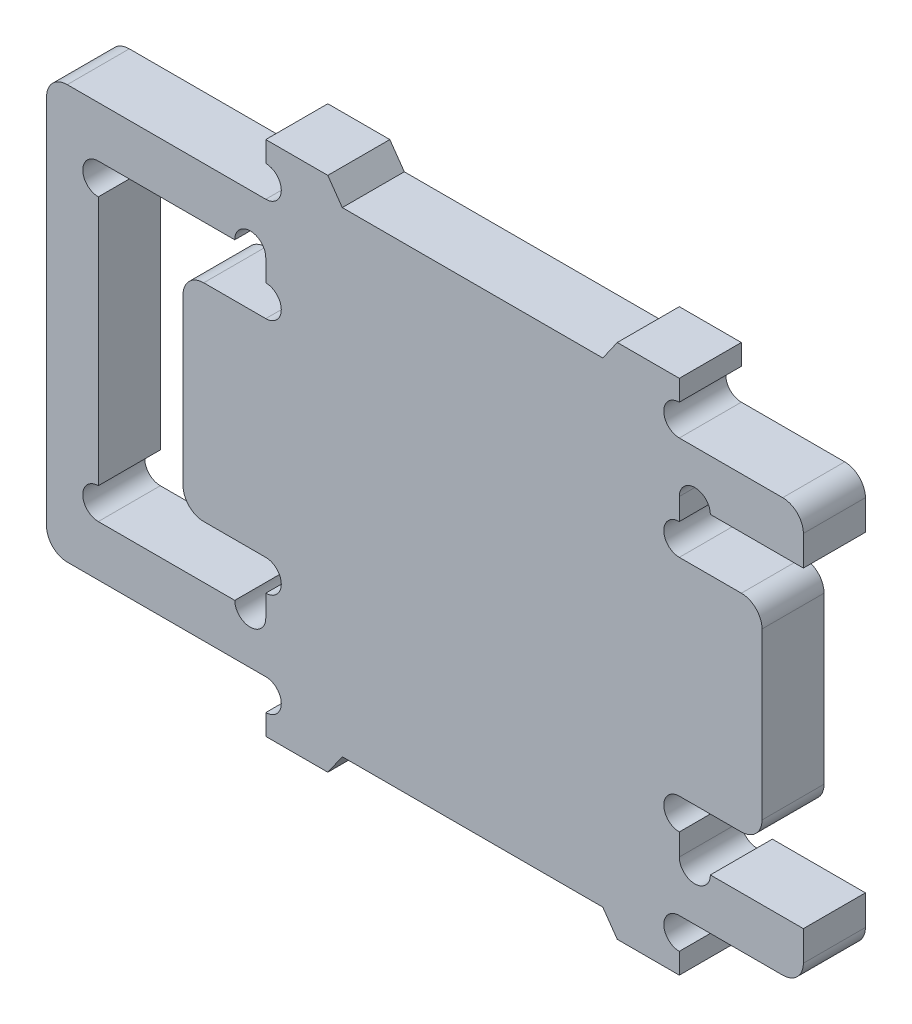
from build123d import *

# Parameters (mm, degrees)
EXTRUDE_1_DEPTH     = 1.5
FILLET_1_R          = 1
SKETCH_3_R          = 0.75
CUT_EXTRUDE_1_DEPTH = 4
SKETCH_4_R          = 0.75
CUT_EXTRUDE_2_DEPTH = 4
SKETCH_5_R          = 0.75
CUT_EXTRUDE_3_DEPTH = 4
CUT_EXTRUDE_6_DEPTH = 4


with BuildPart() as part:
    # 草图1 → 凸台-拉伸1 (new body, symmetric)
    with BuildSketch(Plane.XY):
        Polygon((0, 10), (10.6, 10), (10.6, 12.5), (30.6, 12.5), (30.6, 10), (36.6, 10), (36.6, 7.55), (30.6, 7.55), (30.6, 5), (34.6, 5), (34.6, -5), (30.6, -5), (30.6, -7.55), (36.6, -7.55), (36.6, -10), (30.6, -10), (30.6, -12.5), (10.6, -12.5), (10.6, -10), (0, -10), align=None)
        Polygon((6.6, 5), (10.6, 5), (10.6, 7.55), (2.5, 7.55), (2.5, -7.55), (10.6, -7.55), (10.6, -5), (6.6, -5), align=None, mode=Mode.SUBTRACT)
    extrude(amount=EXTRUDE_1_DEPTH, both=True)

    # 圆角1
    fillet_1_edges = [part.edges().sort_by_distance(p)[0] for p in [
        (0, 10, 0),
        (36.6, 10, 0),
        (34.6, 5, 0),
        (34.6, -5, 0),
        (36.6, -10, 0),
        (0, -10, 0),
        (6.6, -5, 0),
        (6.6, 5, 0),
    ]]
    fillet(fillet_1_edges, radius=FILLET_1_R)

    # 草图3 → 切除-拉伸1 (cut, through all)
    with BuildSketch(Plane.XY.offset(1.5)):
        with Locations((9.85, 7.55)):
            Circle(SKETCH_3_R)
        with Locations((9.85, -7.55)):
            Circle(SKETCH_3_R)
        with Locations((31.35, 7.55)):
            Circle(SKETCH_3_R)
        with Locations((30.6, 5.75)):
            Circle(SKETCH_3_R)
        with Locations((30.6, -5.75)):
            Circle(SKETCH_3_R)
        with Locations((31.35, -7.55)):
            Circle(SKETCH_3_R)
        with Locations((10.6, 5.75)):
            Circle(SKETCH_3_R)
        with Locations((10.6, -5.75)):
            Circle(SKETCH_3_R)
    extrude(amount=-CUT_EXTRUDE_1_DEPTH, mode=Mode.SUBTRACT)

    # 草图4 → 切除-拉伸2 (cut, through all)
    with BuildSketch(Plane.XY.offset(1.5)):
        with Locations((10.6, 10.75)):
            Circle(SKETCH_4_R)
        with Locations((30.6, 10.75)):
            Circle(SKETCH_4_R)
        with Locations((10.6, -10.75)):
            Circle(SKETCH_4_R)
        with Locations((30.6, -10.75)):
            Circle(SKETCH_4_R)
    extrude(amount=-CUT_EXTRUDE_2_DEPTH, mode=Mode.SUBTRACT)

    # 草图5 → 切除-拉伸3 (cut, through all)
    with BuildSketch(Plane.XY.offset(1.5)):
        with Locations((2.5, 6.8)):
            Circle(SKETCH_5_R)
        with Locations((2.5, -6.8)):
            Circle(SKETCH_5_R)
    extrude(amount=-CUT_EXTRUDE_3_DEPTH, mode=Mode.SUBTRACT)

    # 草图8 → 切除-拉伸6 (cut, through all)
    with BuildSketch(Plane.XY.offset(1.5)):
        Polygon((13.6, -12.5), (14.300207538, -11.5), (26.899792462, -11.5), (27.6, -12.5), align=None)
    cut_extrude_6 = extrude(amount=-CUT_EXTRUDE_6_DEPTH, mode=Mode.SUBTRACT)

    # 镜向2: 切除-拉伸6 across plane
    add(cut_extrude_6.mirror(Plane.ZX), mode=Mode.SUBTRACT)


solid = part.part
